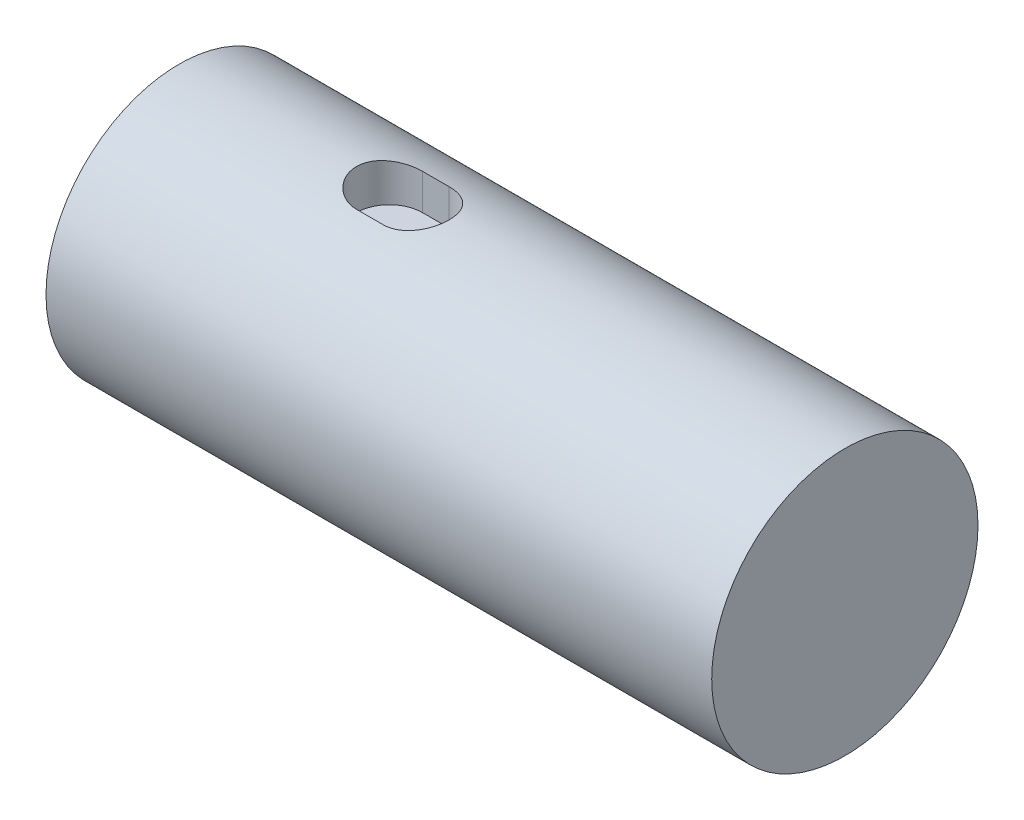
from build123d import *

# Parameters (mm, degrees)
SKICA1_R        = 20
VYSUNOUT1_DEPTH = 100
VYSUNOUT2_START = 20
VYSUNOUT2_DEPTH = 6


with BuildPart() as part:
    # Skica1 → Vysunout1 (new body)
    with BuildSketch(Plane(origin=(0, 0, 0), x_dir=(0, 0, -1), z_dir=(1, 0, 0))):
        Circle(SKICA1_R)
    extrude(amount=VYSUNOUT1_DEPTH)

    # Skica2 → Vysunout2 (cut)
    with BuildSketch(Plane(origin=(0, 0, 0), x_dir=(1, 0, 0), z_dir=(0, 1, 0)).offset(VYSUNOUT2_START)):
        with BuildLine():
            Line((31.593763982, 4.952572563), (35.592424808, 4.952572563))
            ThreePointArc((35.592424808, 4.952572563), (40.544997371, 0), (35.592424808, -4.952572563))
            Line((35.592424808, -4.952572563), (31.593763982, -4.952572563))
            ThreePointArc((31.593763982, -4.952572563), (26.64119142, 0), (31.593763982, 4.952572563))
        make_face()
    extrude(amount=-VYSUNOUT2_DEPTH, mode=Mode.SUBTRACT)


solid = part.part
